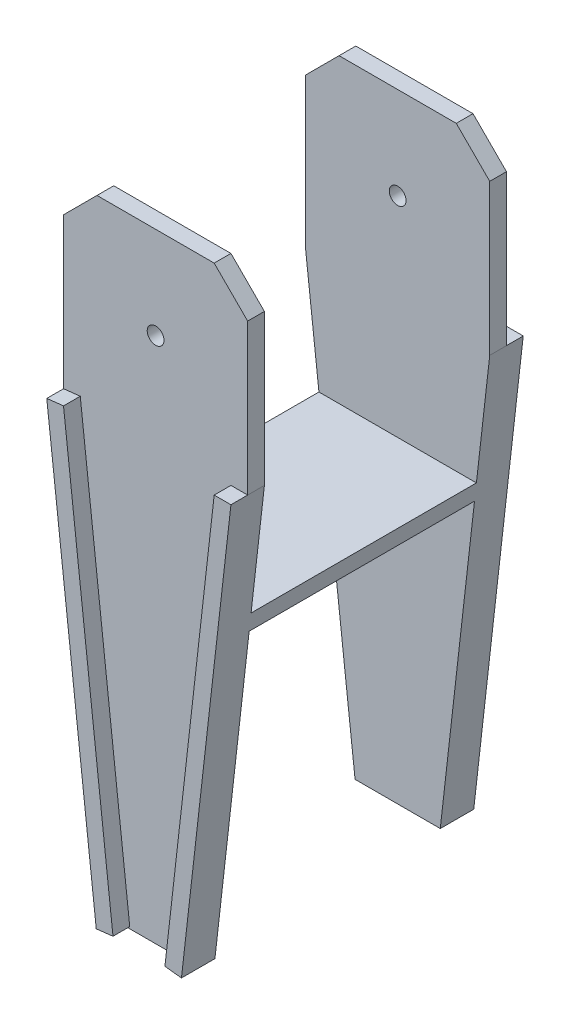
from build123d import *

# Parameters (mm, degrees)
SKETCH1_R           = 2.5
BOSS_EXTRUDE1_DEPTH = 5
SKETCH3_W           = 55
SKETCH3_H           = 5
BOSS_EXTRUDE2_DEPTH = 129.8
SKETCH4_W           = 55
SKETCH4_H           = 5
BOSS_EXTRUDE3_DEPTH = 67.3
SKETCH5_R           = 2.5
BOSS_EXTRUDE4_DEPTH = 5
CUT_EXTRUDE2_REACH  = 79.3
SKETCH7_W           = 0.569216758
SKETCH7_H           = 67.3
CUT_EXTRUDE3_DEPTH  = 5
CUT_EXTRUDE4_REACH  = 166.8
SKETCH8_W           = 30
SKETCH8_H           = 67.3
BOSS_EXTRUDE5_REACH = 74.3
BOSS_EXTRUDE6_DEPTH = 5
BOSS_EXTRUDE7_DEPTH = 5


with BuildPart() as part:
    # Sketch1 → Boss-Extrude1 (new body)
    with BuildSketch(Plane.XY):
        Polygon((-27.5, 17.5), (-17.5, 27.5), (17.5, 27.5), (27.5, 17.5), (27.5, -27.5), (-27.5, -27.5), align=None)
        Circle(SKETCH1_R, mode=Mode.SUBTRACT)
    extrude(amount=BOSS_EXTRUDE1_DEPTH)

    # Sketch3 → Boss-Extrude2 (add)
    with BuildSketch(Plane.XZ.offset(27.5)):
        with Locations((0, 2.5)):
            Rectangle(SKETCH3_W, SKETCH3_H)
    extrude(amount=BOSS_EXTRUDE2_DEPTH)

    # Sketch4 → Boss-Extrude3 (add)
    with BuildSketch(Plane(origin=(0, 0, 0), x_dir=(-1, 0, 0), z_dir=(0, 0, -1))):
        with Locations((0, -134.8)):
            Rectangle(SKETCH4_W, SKETCH4_H)
    extrude(amount=BOSS_EXTRUDE3_DEPTH)

    # Sketch5 → Boss-Extrude4 (add)
    with BuildSketch(Plane(origin=(0, 0, -67.3), x_dir=(-1, 0, 0), z_dir=(0, 0, -1))):
        Polygon((-27.5, -157.3), (27.5, -157.3), (27.5, 17.5), (17.5, 27.5), (-17.5, 27.5), (-27.5, 17.5), align=None)
        Circle(SKETCH5_R, mode=Mode.SUBTRACT)
    extrude(amount=BOSS_EXTRUDE4_DEPTH)

    # Sketch6 → Cut-Extrude2 (cut, up to next)
    with BuildSketch(Plane.XY.offset(5), mode=Mode.PRIVATE) as cut_extrude2_sk1:
        Polygon((-12.723132969, -157.3), (-27.5, -27.5), (-27.5, -157.3), align=None)
    cut_extrude2_tool1 = extrude(cut_extrude2_sk1.sketch, amount=-CUT_EXTRUDE2_REACH, mode=Mode.PRIVATE) & part.part
    add(cut_extrude2_tool1.solids().sort_by_distance((-22.574378, -114.033333, 5))[0], mode=Mode.SUBTRACT)
    # Sketch6 → Cut-Extrude2 (cut, up to next)
    with BuildSketch(Plane.XY.offset(5), mode=Mode.PRIVATE) as cut_extrude2_sk2:
        Polygon((27.5, -27.5), (12.723132969, -157.3), (27.5, -157.3), align=None)
    cut_extrude2_tool2 = extrude(cut_extrude2_sk2.sketch, amount=-CUT_EXTRUDE2_REACH, mode=Mode.PRIVATE) & part.part
    add(cut_extrude2_tool2.solids().sort_by_distance((22.574378, -114.033333, 5))[0], mode=Mode.SUBTRACT)

    # Sketch7 → Cut-Extrude3 (cut)
    with BuildSketch(Plane.XZ.offset(137.3)):
        with Locations((-15.284608379, -33.65)):
            Rectangle(SKETCH7_W, SKETCH7_H)
        with Locations((15.284608379, -33.65)):
            Rectangle(SKETCH7_W, SKETCH7_H)
    extrude(amount=-CUT_EXTRUDE3_DEPTH, mode=Mode.SUBTRACT)

    # Sketch8 → Cut-Extrude4 (cut, up to next)
    with BuildSketch(Plane.XZ.offset(137.3), mode=Mode.PRIVATE) as cut_extrude4_sk1:
        with Locations((0, -33.65)):
            Rectangle(SKETCH8_W, SKETCH8_H)
    cut_extrude4_tool1 = extrude(cut_extrude4_sk1.sketch, amount=-CUT_EXTRUDE4_REACH, mode=Mode.PRIVATE) & part.part
    add(cut_extrude4_tool1.solids().sort_by_distance((0, -137.3, -33.65))[0], mode=Mode.SUBTRACT)

    # Sketch9 → Boss-Extrude5 (add, up to next)
    with BuildSketch(Plane(origin=(0, 0, 0), x_dir=(-1, 0, 0), z_dir=(0, 0, -1)), mode=Mode.PRIVATE) as boss_extrude5_sk1:
        Polygon((-23.515482696, -62.5), (23.515482696, -62.5), (22.946265938, -67.5), (-22.946265938, -67.5), align=None)
    boss_extrude5_tool1 = extrude(boss_extrude5_sk1.sketch, amount=BOSS_EXTRUDE5_REACH, mode=Mode.PRIVATE) - part.part
    add(boss_extrude5_tool1.solids().sort_by_distance((0, -64.989791, 0))[0])

    # Sketch10 → Boss-Extrude6 (add)
    with BuildSketch(Plane.XY.offset(5)):
        Polygon((27.5, -27.5), (12.723132969, -157.3), (7.78710541, -156.738066079), (22.5, -27.5), align=None)
        Polygon((-27.5, -27.5), (-12.723132969, -157.3), (-7.723132969, -156.730783242), (-22.5, -26.930783242), align=None)
    extrude(amount=BOSS_EXTRUDE6_DEPTH)

    # Sketch11 → Boss-Extrude7 (add)
    with BuildSketch(Plane(origin=(0, 0, -72.3), x_dir=(-1, 0, 0), z_dir=(0, 0, -1))):
        Polygon((-27.5, -27.5), (-12.723132969, -157.3), (-7.78710541, -156.738066079), (-22.5, -27.5), align=None)
        Polygon((27.5, -27.5), (12.723132969, -157.3), (7.755222161, -156.734436383), (22.532089192, -26.934436383), align=None)
    extrude(amount=BOSS_EXTRUDE7_DEPTH)


solid = part.part
